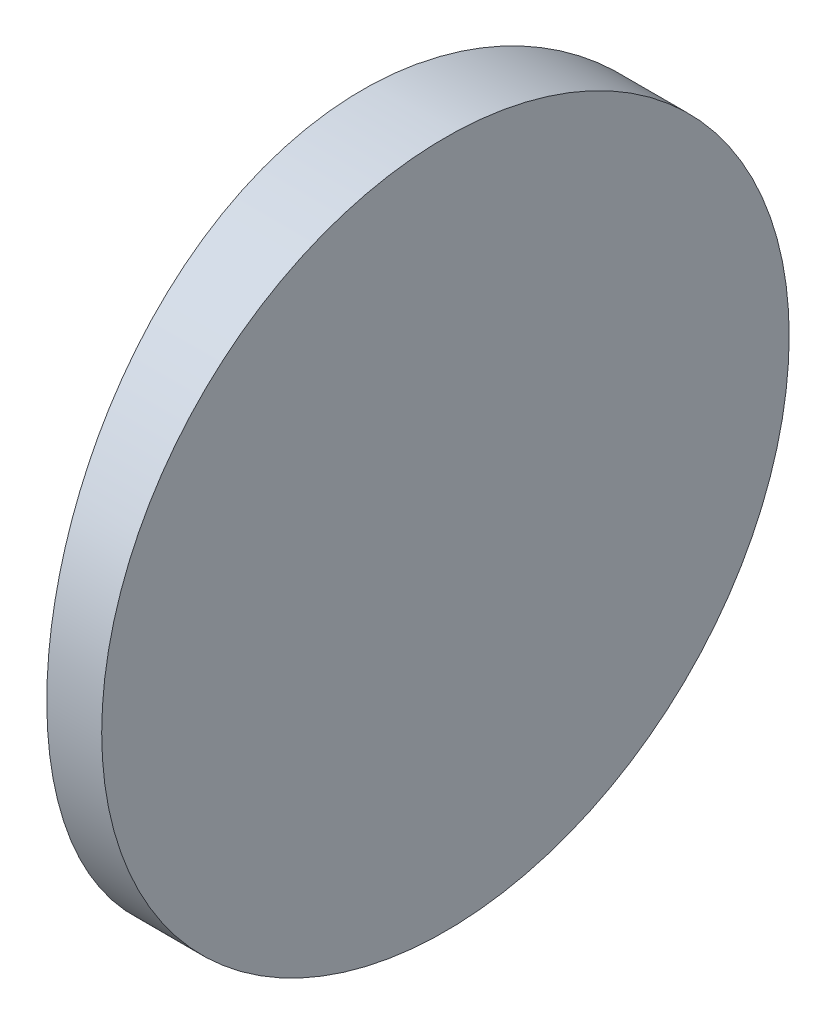
from build123d import *

# Parameters (mm, degrees)
EXTRUDE_1_DEPTH     = 25
CUT_EXTRUDE_8_DEPTH = 12.7


with BuildPart() as part:
    # 草图1 → 凸台-拉伸1 (new body)
    with BuildSketch(Plane(origin=(0, 0, 0), x_dir=(1, 0, 0), z_dir=(0, 1, 0))):
        with BuildLine():
            Line((-72.180751268, 12.5), (-70.184795665, 12.5))
            Line((-70.184795665, 12.5), (-70.184795665, -12.5))
            Line((-70.184795665, -12.5), (-72.180751268, -12.5))
            ThreePointArc((-72.180751268, -12.5), (-73.194795665, 0), (-72.180751268, 12.5))
        make_face()
    extrude(amount=EXTRUDE_1_DEPTH)

    # 草图2 → 切除-拉伸8 (cut)
    with BuildSketch(Plane(origin=(-70.184795665, 0, 0), x_dir=(0, 0, -1), z_dir=(1, 0, 0))):
        with BuildLine():
            Line((-12.5, 25), (-12.5, 12.5))
            ThreePointArc((-12.5, 12.5), (-8.838834765, 21.338834765), (0, 25))
            Line((0, 25), (-12.5, 25))
        make_face()
        with BuildLine():
            ThreePointArc((0, 25), (8.838834765, 21.338834765), (12.5, 12.5))
            Line((12.5, 12.5), (12.5, 25))
            Line((12.5, 25), (0, 25))
        make_face()
        with BuildLine():
            ThreePointArc((12.5, 12.5), (8.838834765, 3.661165235), (0, 0))
            Line((0, 0), (12.5, 0))
            Line((12.5, 0), (12.5, 12.5))
        make_face()
        with BuildLine():
            Line((-12.5, 12.5), (-12.5, 0))
            Line((-12.5, 0), (0, 0))
            ThreePointArc((0, 0), (-8.838834765, 3.661165235), (-12.5, 12.5))
        make_face()
    extrude(amount=-CUT_EXTRUDE_8_DEPTH, mode=Mode.SUBTRACT)


solid = part.part
